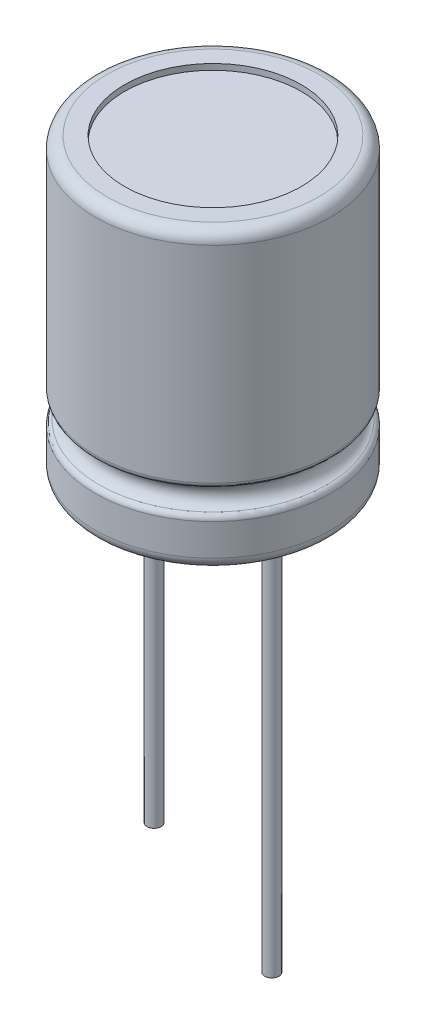
from build123d import *

# Parameters (mm, degrees)
SKETCH1_R           = 5
BASE_EXTRUDE_DEPTH  = 12.5
FILLET1_R           = 0.5
FILLET2_R           = 0.25
SKETCH4_R           = 3.75
CUT_EXTRUDE1_DEPTH  = 0.25
SKETCH3_R           = 0.3
BOSS_EXTRUDE1_DEPTH = 17.25
SKETCH5_R           = 0.3
CUT_EXTRUDE2_DEPTH  = 3
SKETCH6_R           = 3.75
CUT_EXTRUDE3_DEPTH  = 0.25


with BuildPart() as part:
    # Sketch1 → Base-Extrude (new body)
    with BuildSketch(Plane(origin=(0, 0, 0), x_dir=(1, 0, 0), z_dir=(0, 1, 0))):
        with Locations(Location((0, 0, 0), (0, 0, 270))):  # turned: the seam where the file's is
            Circle(SKETCH1_R)
    extrude(amount=BASE_EXTRUDE_DEPTH)

    # Sketch2 → Cut-Revolve1 (revolve, cut)
    with BuildSketch(Plane(origin=(0, 0, 0), x_dir=(0, 0, -1), z_dir=(1, 0, 0)), mode=Mode.PRIVATE) as cut_revolve1_sk:
        with BuildLine():
            Line((-5, 3.053185949), (-5, 2.053185949))
            ThreePointArc((-5, 2.053185949), (-4.5, 2.553185949), (-5, 3.053185949))
        make_face()
    revolve(cut_revolve1_sk.sketch.rotate(Axis((0, 0, 0), (0, 1, 0)), 180), axis=Axis((0, 0, 0), (0, 1, 0)), mode=Mode.SUBTRACT)  # turned: the seam where the file's is

    # Fillet1
    fillet1_edges = [part.edges().sort_by_distance(p)[0] for p in [
        (0, 0, -5),
        (0, 12.5, -5),
    ]]
    fillet(fillet1_edges, radius=FILLET1_R)

    # Fillet2
    fillet2_edges = [part.edges().sort_by_distance(p)[0] for p in [
        (-5, 2.053185949, 0),
        (-5, 3.053185949, 0),
    ]]
    fillet(fillet2_edges, radius=FILLET2_R)

    # Sketch4 → Cut-Extrude1 (cut)
    with BuildSketch(Plane.XZ):
        with Locations(Location((0, 0, 0), (0, 0, 270))):  # turned: the seam where the file's is
            Circle(SKETCH4_R)
    extrude(amount=-CUT_EXTRUDE1_DEPTH, mode=Mode.SUBTRACT)

    # Sketch3 → Boss-Extrude1 (add)
    with BuildSketch(Plane.XZ.offset(-0.25)):
        with Locations(Location((-2.5, 0, 0), (0, 0, 270))):  # turned: the seam where the file's is
            Circle(SKETCH3_R)
        with Locations(Location((2.5, 0, 0), (0, 0, 270))):  # turned: the seam where the file's is
            Circle(SKETCH3_R)
    extrude(amount=BOSS_EXTRUDE1_DEPTH)

    # Sketch5 → Cut-Extrude2 (cut)
    with BuildSketch(Plane.XZ.offset(17)):
        with Locations(Location((-2.5, 0, 0), (0, 0, 270))):  # turned: the seam where the file's is
            Circle(SKETCH5_R)
    extrude(amount=-CUT_EXTRUDE2_DEPTH, mode=Mode.SUBTRACT)

    # Sketch6 → Cut-Extrude3 (cut)
    with BuildSketch(Plane(origin=(0, 12.5, 0), x_dir=(-1, 0, 0), z_dir=(0, 1, 0))):
        with Locations(Location((0, 0, 0), (0, 0, 270))):  # turned: the seam where the file's is
            Circle(SKETCH6_R)
    extrude(amount=-CUT_EXTRUDE3_DEPTH, mode=Mode.SUBTRACT)


solid = part.part
